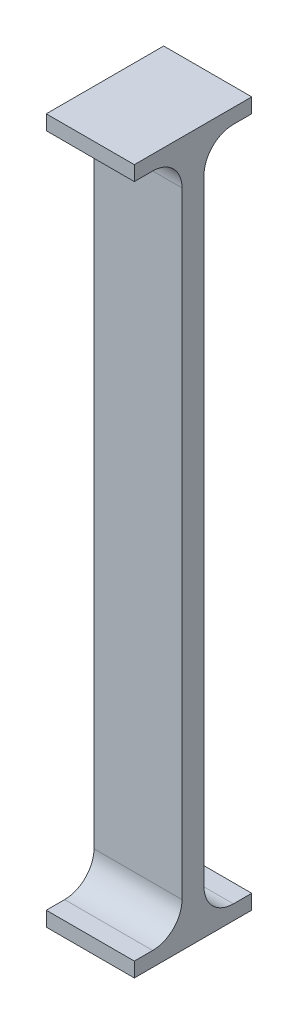
from build123d import *

# Parameters (mm, degrees)
SKETCH1_W           = 30
SKETCH1_H           = 239.95
BOSS_EXTRUDE1_DEPTH = 3.75
SKETCH2_W           = 30
SKETCH2_H           = 5
BOSS_EXTRUDE2_DEPTH = 20
SKETCH3_W           = 30
SKETCH3_H           = 5
BOSS_EXTRUDE3_DEPTH = 20
FILLET1_R           = 10
FILLET2_R           = 10


with BuildPart() as part:
    # Sketch1 → Boss-Extrude1 (new body, symmetric)
    with BuildSketch(Plane.XY):
        with Locations((0, 119.975)):
            Rectangle(SKETCH1_W, SKETCH1_H)
    extrude(amount=BOSS_EXTRUDE1_DEPTH, both=True)

    # Sketch2 → Boss-Extrude2 (add, symmetric)
    with BuildSketch(Plane.XY):
        with Locations((0, 2.5)):
            Rectangle(SKETCH2_W, SKETCH2_H)
    extrude(amount=BOSS_EXTRUDE2_DEPTH, both=True)

    # Sketch3 → Boss-Extrude3 (add, symmetric)
    with BuildSketch(Plane.XY):
        with Locations((0, 237.45)):
            Rectangle(SKETCH3_W, SKETCH3_H)
    extrude(amount=BOSS_EXTRUDE3_DEPTH, both=True)

    # Fillet1
    fillet1_edges = [part.edges().sort_by_distance(p)[0] for p in [
        (0, 234.95, 3.75),
        (0, 234.95, -3.75),
    ]]
    fillet(fillet1_edges, radius=FILLET1_R)

    # Fillet2
    fillet2_edges = [part.edges().sort_by_distance(p)[0] for p in [
        (0, 5, -3.75),
        (0, 5, 3.75),
    ]]
    fillet(fillet2_edges, radius=FILLET2_R)


solid = part.part
